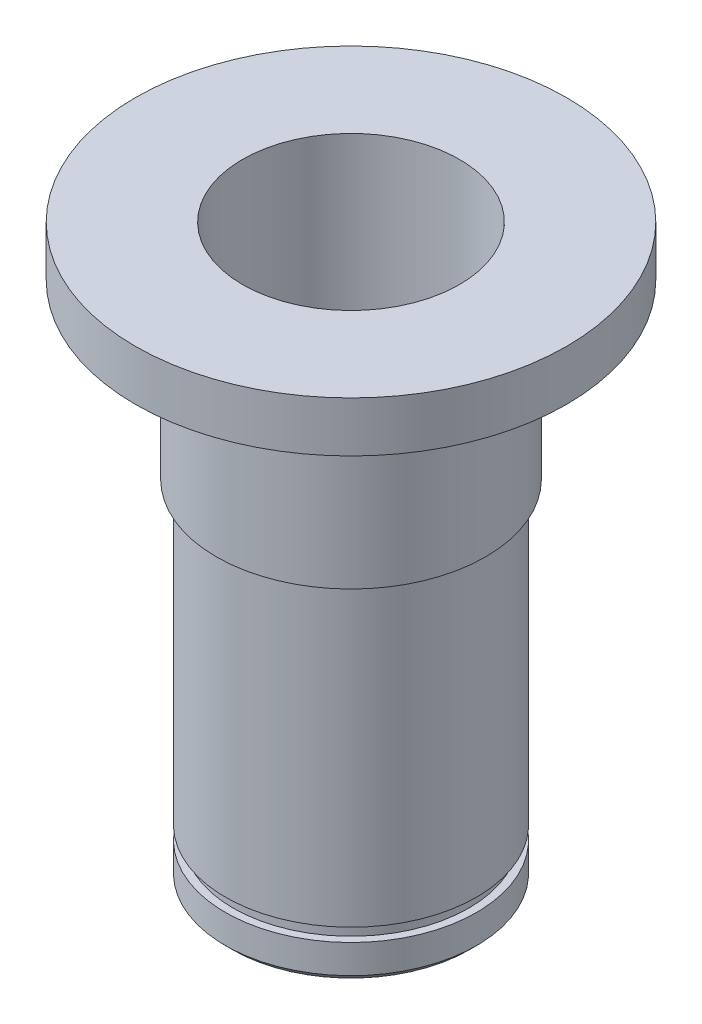
from build123d import *

# Parameters (mm, degrees)
CHAMFER1_SIZE = 0.635
SKETCH3_W     = 0.6731
SKETCH3_H     = 1.1684
FILLET1_R     = 0.396875


with BuildPart() as part:
    # Sketch1 → Revolve1 (revolve)
    with BuildSketch(Plane.XY, mode=Mode.PRIVATE) as revolve1_sk:
        Polygon((-19.05, 50.4825), (-19.05, 46.0375), (-11.8999, 46.0375), (-11.8999, 30.7975), (-11.0998, 30.7975), (-11.0998, 0), (-9.5885, 0), (-9.5885, 50.4825), align=None)
    revolve(revolve1_sk.sketch.rotate(Axis((0, 18.282782329, 0), (0, -1, 0)), 270), axis=Axis((0, 18.282782329, 0), (0, -1, 0)))  # turned: the seam where the file's is

    # Chamfer1
    chamfer1_edges = [part.edges().sort_by_distance(p)[0] for p in [
        (0, 0, -11.0998),
    ]]
    chamfer(chamfer1_edges, length=CHAMFER1_SIZE)

    # Sketch3 → Cut-Revolve1 (revolve, cut)
    with BuildSketch(Plane.XY, mode=Mode.PRIVATE) as cut_revolve1_sk:
        with Locations((-10.76325, 3.7592)):
            Rectangle(SKETCH3_W, SKETCH3_H)
    revolve(cut_revolve1_sk.sketch.rotate(Axis((0, -2.070057214, 0), (0, 1, 0)), 90), axis=Axis((0, -2.070057214, 0), (0, 1, 0)), mode=Mode.SUBTRACT)  # turned: the seam where the file's is

    # Fillet1
    fillet1_edges = [part.edges().sort_by_distance(p)[0] for p in [
        (0, 46.0375, -11.8999),
        (0, 30.7975, -11.0998),
    ]]
    fillet(fillet1_edges, radius=FILLET1_R)


solid = part.part
